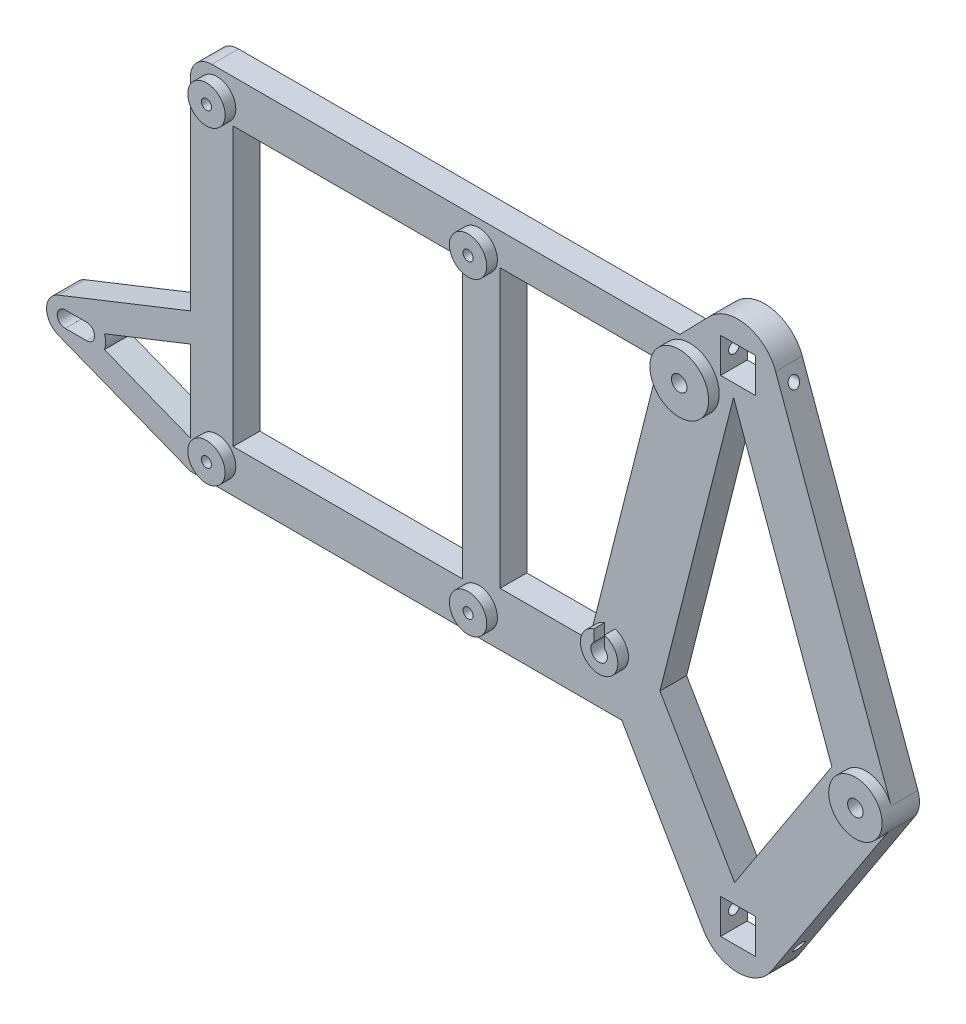
from build123d import *

# Parameters (mm, degrees)
SKETCH1_R               = 0.95
SKETCH1_W               = 6.5
SKETCH1_H               = 6.5
SKETCH1_R_2             = 1.55
SKETCH1_R_3             = 1.45
SKETCH1_W_2             = 43
SKETCH1_H_2             = 52
BOSS_EXTRUDE1_DEPTH     = 5
SKETCH3_R               = 5
SKETCH3_R_2             = 1.45
SKETCH3_R_3             = 5.5
SKETCH3_R_4             = 3.5
SKETCH3_R_5             = 0.95
BOSS_EXTRUDE3_DEPTH     = 2
CUT_EXTRUDE1_DEPTH      = 10
SKETCH6_R               = 1
CUT_EXTRUDE2_DEPTH      = 14.13
CUT_EXTRUDE2_DEPTH_BACK = 10


with BuildPart() as part:
    # Sketch1 → Boss-Extrude1 (new body)
    with BuildSketch(Plane.XY):
        with BuildLine():
            Line((13.24210093, 18.56), (28.512575376, -7.763418891))
            ThreePointArc((28.512575376, -7.763418891), (34.802937336, -11.49741064), (41.280767541, -8.099019285))
            Line((41.280767541, -8.099019285), (63.187178361, 25.467320477))
            ThreePointArc((63.187178361, 25.467320477), (63.966953059, 27.626085973), (63.700028418, 29.905793912))
            Line((63.700028418, 29.905793912), (42.050042627, 89.558690868))
            ThreePointArc((42.050042627, 89.558690868), (36.572238317, 94.333353031), (29.618521803, 92.223953715))
            Line((29.618521803, 92.223953715), (24.120361081, 86.56))
            Line((24.120361081, 86.56), (-63.55, 86.56))
            ThreePointArc((-63.55, 86.56), (-66.378427125, 85.388427125), (-67.55, 82.56))
            Line((-67.55, 82.56), (-67.55, 44.56))
            Line((-67.55, 44.56), (-92.289702732, 34.753715855))
            ThreePointArc((-92.289702732, 34.753715855), (-94.499992282, 31.492649998), (-92.276025776, 28.240896102))
            Line((-92.276025776, 28.240896102), (-67.55, 18.56))
            Line((-67.55, 18.56), (13.24210093, 18.56))
        make_face()
        with Locations((-62.55, 23.56)):
            Circle(SKETCH1_R, mode=Mode.SUBTRACT)
        with BuildLine():
            ThreePointArc((-87, 32.997152184), (-85.5, 31.497152184), (-87, 29.997152184))
            Line((-87, 29.997152184), (-91, 29.997152184))
            Line((-91, 29.997152184), (-91, 30))
            ThreePointArc((-91, 30), (-92.5, 31.5), (-91, 33))
            Line((-91, 33), (-87, 33))
            Line((-87, 33), (-87, 32.997152184))
        make_face(mode=Mode.SUBTRACT)
        with BuildLine():
            Line((-67.55, 23.929574136), (-83.648509217, 30.232568258))
            ThreePointArc((-83.648509217, 30.232568258), (-83.407620833, 31.515944037), (-83.65389726, 32.798296766))
            Line((-83.65389726, 32.798296766), (-67.55, 39.18153403))
            Line((-67.55, 39.18153403), (-67.55, 23.929574136))
        make_face(mode=Mode.SUBTRACT)
        with Locations((35, -4)):
            Rectangle(SKETCH1_W, SKETCH1_H, mode=Mode.SUBTRACT)
        with Locations((11, 29.4)):
            Circle(SKETCH1_R_2, mode=Mode.SUBTRACT)
        with Locations((59, 28.2)):
            Circle(SKETCH1_R_3, mode=Mode.SUBTRACT)
        with Locations((-38.05, 52.56)):
            Rectangle(SKETCH1_W_2, SKETCH1_H_2, mode=Mode.SUBTRACT)
        with Locations((-62.55, 81.56)):
            Circle(SKETCH1_R, mode=Mode.SUBTRACT)
        with BuildLine():
            ThreePointArc((7.606653519, 30.257437846), (7.500011538, 29.408987159), (7.602294892, 28.56))
            Line((7.602294892, 28.56), (-9.55, 28.56))
            Line((-9.55, 28.56), (-9.55, 80.56))
            Line((-9.55, 80.56), (20.317209538, 80.56))
            Line((20.317209538, 80.56), (7.606653519, 30.257437846))
        make_face(mode=Mode.SUBTRACT)
        with Locations((-13.55, 81.56)):
            Circle(SKETCH1_R, mode=Mode.SUBTRACT)
        with Locations((26, 80.6)):
            Circle(SKETCH1_R_3, mode=Mode.SUBTRACT)
        with Locations((35, 87)):
            Rectangle(SKETCH1_W, SKETCH1_H, mode=Mode.SUBTRACT)
        with Locations((-13.55, 23.56)):
            Circle(SKETCH1_R, mode=Mode.SUBTRACT)
    extrude(amount=BOSS_EXTRUDE1_DEPTH)

    # Sketch3 → Boss-Extrude3 (add)
    with BuildSketch(Plane.XY.offset(5)):
        with Locations((59, 28.2)):
            Circle(SKETCH3_R)
        with Locations((59, 28.2)):
            Circle(SKETCH3_R_2, mode=Mode.SUBTRACT)
        with Locations((26, 80.6)):
            Circle(SKETCH3_R_3)
        with Locations((26, 80.6)):
            Circle(SKETCH3_R_2, mode=Mode.SUBTRACT)
        with BuildLine():
            ThreePointArc((12.55, 29.4), (10.347121757, 27.994208408), (10, 30.584271928))
            Line((10, 30.584271928), (10, 32.754101966))
            ThreePointArc((10, 32.754101966), (8.473400258, 31.822043299), (7.606653519, 30.257437846))
            ThreePointArc((7.606653519, 30.257437846), (7.500011538, 29.408987159), (7.602294892, 28.56))
            ThreePointArc((7.602294892, 28.56), (13.415547613, 26.867189362), (12, 32.754101966))
            Line((12, 32.754101966), (12, 30.584271928))
            ThreePointArc((12, 30.584271928), (12.405791592, 30.052878243), (12.55, 29.4))
        make_face()
        with Locations((-13.55, 23.56)):
            Circle(SKETCH3_R_4)
        with Locations((-13.55, 23.56)):
            Circle(SKETCH3_R_5, mode=Mode.SUBTRACT)
        with Locations((-62.55, 23.56)):
            Circle(SKETCH3_R_4)
        with Locations((-62.55, 23.56)):
            Circle(SKETCH3_R_5, mode=Mode.SUBTRACT)
        with Locations((-62.55, 81.56)):
            Circle(SKETCH3_R_4)
        with Locations((-62.55, 81.56)):
            Circle(SKETCH3_R_5, mode=Mode.SUBTRACT)
        with Locations((-13.55, 81.56)):
            Circle(SKETCH3_R_4)
        with Locations((-13.55, 81.56)):
            Circle(SKETCH3_R_5, mode=Mode.SUBTRACT)
    extrude(amount=BOSS_EXTRUDE3_DEPTH)

    # Sketch4 → Cut-Extrude1 (cut)
    with BuildSketch(Plane.XY.offset(5)):
        Polygon((34.174437675, 81.42265859), (52.588350326, 30.686217258), (34.375314724, 2.779092439), (20.392987639, 26.881988144), align=None)
    extrude(amount=-CUT_EXTRUDE1_DEPTH, mode=Mode.SUBTRACT)

    # Sketch6 → Cut-Extrude2 (cut, two sides)
    with BuildSketch(Plane.ZY.offset(-38.25)) as cut_extrude2_sk:
        with Locations((2.5, -4)):
            Circle(SKETCH6_R)
        with Locations((2.5, 87)):
            Circle(SKETCH6_R)
    extrude(amount=CUT_EXTRUDE2_DEPTH, mode=Mode.SUBTRACT)
    extrude(cut_extrude2_sk.sketch, amount=-CUT_EXTRUDE2_DEPTH_BACK, mode=Mode.SUBTRACT)


solid = part.part
